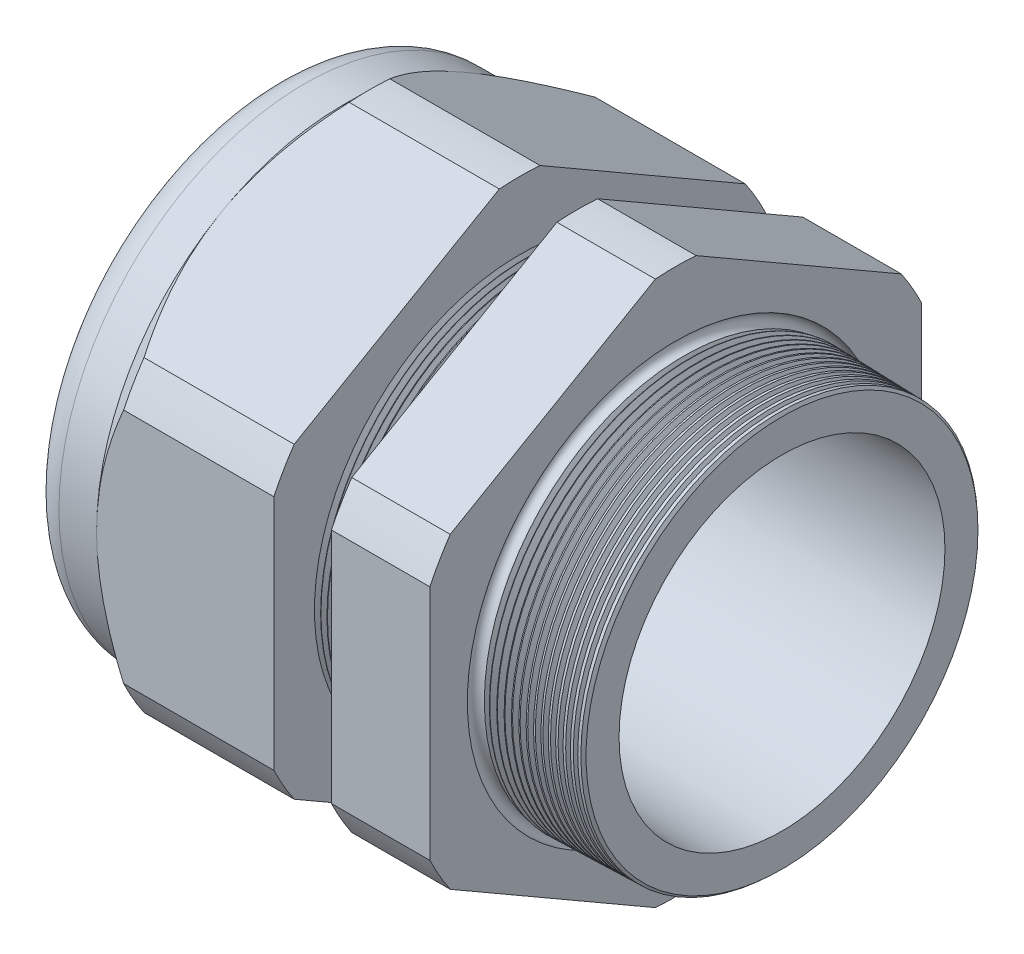
from build123d import *

# Parameters (mm, degrees)
SKETCH12_OUTSIDE_W = 157.992
SKETCH12_OUTSIDE_H = 157.992
CUT_EXTRUDE2_DEPTH = 54.5760168
FILLET4_R          = 3.81
SKETCH19_OUTSIDE_W = 91.722
SKETCH19_OUTSIDE_H = 98.316
SKETCH19_OUTSIDE_R = 29.972
CUT_EXTRUDE3_DEPTH = 3.99796
CUT_EXTRUDE3_DRAFT = -45
CHAMFER1_SIZE      = 0.260919487
CHAMFER1_SIZE2     = 0.254
SKETCH21_R         = 19.05
PLUG_DEPTH         = 11.43
SKETCH22_R         = 18.796
CUT_EXTRUDE4_DEPTH = 0.508
LPATTERN1_COUNT    = 9
LPATTERN1_PITCH    = 0.762
LPATTERN2_COUNT    = 15
LPATTERN2_PITCH    = 0.889
SKETCH32_R         = 0.889


with BuildPart() as part:
    # Sketch10 → Revolve2 (revolve)
    with BuildSketch(Plane.XY, mode=Mode.PRIVATE) as revolve2_sk:
        Polygon((-56.896, 19.05), (-26.89359112, 19.05), (5.08, 19.863742051), (5.08, 24.181742051), (-7.874, 24.520954479), (-7.874, 59.944), (-19.873976, 59.944), (-19.873976, 24.835184909), (-26.89359112, 25.019), (-26.89359112, 59.944), (-48.4960168, 59.944), (-48.4960168, 29.972), (-56.896, 29.972), align=None)
    revolve(revolve2_sk.sketch.rotate(Axis((0, 0, 0), (-1, 0, 0)), 90), axis=Axis((0, 0, 0), (-1, 0, 0)))  # turned: the seam where the file's is

    # Sketch12 outside → Cut-Extrude2 (cut, through all)
    with BuildSketch(Plane.ZY.offset(48.4960168)):
        Rectangle(SKETCH12_OUTSIDE_W, SKETCH12_OUTSIDE_H)
        with BuildLine():
            Line((-2.480993384, 33.176282338), (-27.491006616, 18.736744466))
            ThreePointArc((-27.491006616, 18.736744466), (-28.811729876, 16.63446), (-29.972, 14.439537872))
            Line((-29.972, 14.439537872), (-29.972, -14.439537872))
            ThreePointArc((-29.972, -14.439537872), (-28.811729876, -16.63446), (-27.491006616, -18.736744466))
            Line((-27.491006616, -18.736744466), (-2.480993384, -33.176282338))
            ThreePointArc((-2.480993384, -33.176282338), (0, -33.26892), (2.480993384, -33.176282338))
            Line((2.480993384, -33.176282338), (27.491006616, -18.736744466))
            ThreePointArc((27.491006616, -18.736744466), (28.811729876, -16.63446), (29.972, -14.439537872))
            Line((29.972, -14.439537872), (29.972, 14.439537872))
            ThreePointArc((29.972, 14.439537872), (28.811729876, 16.63446), (27.491006616, 18.736744466))
            Line((27.491006616, 18.736744466), (2.480993384, 33.176282338))
            ThreePointArc((2.480993384, 33.176282338), (0, 33.26892), (-2.480993384, 33.176282338))
        make_face(mode=Mode.SUBTRACT)
    extrude(amount=-CUT_EXTRUDE2_DEPTH, mode=Mode.SUBTRACT)

    # Fillet4
    fillet4_edges = [part.edges().sort_by_distance(p)[0] for p in [
        (-56.896, 0, 29.972),
    ]]
    fillet(fillet4_edges, radius=FILLET4_R)


with BuildPart() as cut_extrude3_tool:
    # Sketch19 outside → Cut-Extrude3 (with draft: the straight prism first)
    with BuildSketch(Plane.ZY.offset(48.4960168)):
        Rectangle(SKETCH19_OUTSIDE_W, SKETCH19_OUTSIDE_H)
        Circle(SKETCH19_OUTSIDE_R, mode=Mode.SUBTRACT)
    extrude(amount=-CUT_EXTRUDE3_DEPTH)
    # Cut-Extrude3: the draft: its side faces are tilted about the plane it starts from
    cut_extrude3_sides = [cut_extrude3_tool.faces().sort_by_distance(p)[0] for p in [
        (-46.4970368, -49.158, 0),
        (-46.4970368, 0, 45.861),
        (-46.4970368, 49.158, 0),
        (-46.4970368, 0, -45.861),
        (-46.4970368, 0, -29.972),
    ]]
    draft(cut_extrude3_sides, Plane.ZY.offset(48.4960168), CUT_EXTRUDE3_DRAFT)


with BuildPart() as part_1:
    add(part.part)

    # Cut-Extrude3: cut by cut_extrude3_tool
    add(cut_extrude3_tool.part, mode=Mode.SUBTRACT)

    # Chamfer1
    chamfer1_edges = [part_1.edges().sort_by_distance(p)[0] for p in [
        (5.08, 0, 24.181742051),
    ]]
    chamfer1_side = [part_1.faces().sort_by_distance(p)[0] for p in [
        (5.08, 0, 20.547705002),
    ]]
    chamfer(chamfer1_edges, length=CHAMFER1_SIZE, length2=CHAMFER1_SIZE2, reference=chamfer1_side[0])

    # Sketch29 → Cut-Revolve1 (revolve, cut)
    with BuildSketch(Plane.XY, mode=Mode.PRIVATE) as cut_revolve1_sk:
        Polygon((-26.89359112, 25.019), (-26.160607539, 24.999806149), (-26.543721692, 24.374620673), align=None)
    cut_revolve1 = revolve(cut_revolve1_sk.sketch.rotate(Axis((0, 0, 0), (-1, 0, 0)), 90), axis=Axis((0, 0, 0), (-1, 0, 0)), mode=Mode.SUBTRACT)  # turned: the seam where the file's is

    # LPattern1: Cut-Revolve1 ×9
    with Locations(*[(i * LPATTERN1_PITCH, 0, 0) for i in range(1, LPATTERN1_COUNT)]):
        add(cut_revolve1, mode=Mode.SUBTRACT)

    # Sketch30 → Cut-Revolve2 (revolve, cut)
    with BuildSketch(Plane.XY, mode=Mode.PRIVATE) as cut_revolve2_sk:
        Polygon((-7.874, 24.520954479), (-6.994419703, 24.497921858), (-7.454156686, 23.747699287), align=None)
    cut_revolve2 = revolve(cut_revolve2_sk.sketch.rotate(Axis((0, 0, 0), (-1, 0, 0)), 270), axis=Axis((0, 0, 0), (-1, 0, 0)), mode=Mode.SUBTRACT)  # turned: the seam where the file's is

    # LPattern2: Cut-Revolve2 ×15
    with Locations(*[(i * LPATTERN2_PITCH, 0, 0) for i in range(1, LPATTERN2_COUNT)]):
        add(cut_revolve2, mode=Mode.SUBTRACT)

    # Sketch32 → Cut-Revolve3 (revolve, cut)
    with BuildSketch(Plane.XY, mode=Mode.PRIVATE) as cut_revolve3_sk:
        with Locations((-7.747, 24.520954479)):
            Circle(SKETCH32_R)
    revolve(cut_revolve3_sk.sketch.rotate(Axis((0, 0, 0), (-1, 0, 0)), 270), axis=Axis((0, 0, 0), (-1, 0, 0)), mode=Mode.SUBTRACT)  # turned: the seam where the file's is


with BuildPart() as body_2:
    # Sketch21 → plug (new body)
    with BuildSketch(Plane.ZY.offset(56.896)):
        Circle(SKETCH21_R)
    extrude(amount=-PLUG_DEPTH)

    # Sketch22 → Cut-Extrude4 (cut)
    with BuildSketch(Plane.ZY.offset(56.896)):
        Circle(SKETCH22_R)
    extrude(amount=-CUT_EXTRUDE4_DEPTH, mode=Mode.SUBTRACT)


solid = Compound([part_1.part, body_2.part])
